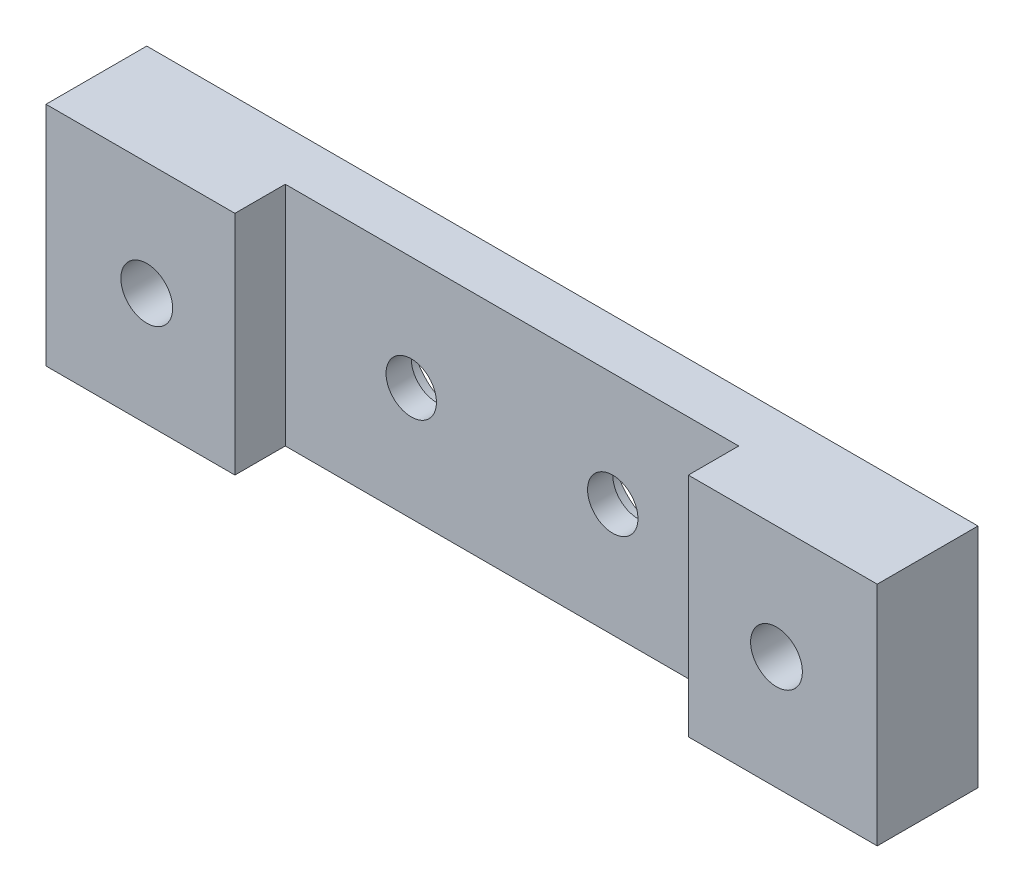
from build123d import *

# Parameters (mm, degrees)
BOSS_EXTRUDE1_DEPTH      = 28.575
HOLE1_D                  = 6.35
HOLE1_DEPTH              = 12.7
HOLE1_CBORE_D            = 12.7
HOLE1_CBORE_DEPTH        = 3.175
HOLE1_TIP                = 1.907732465
F_5_16_18_TAPPED_HOLE1_D = 6.5278


with BuildPart() as part:
    # Sketch1 → Boss-Extrude1 (new body)
    with BuildSketch(Plane(origin=(0, 0, 0), x_dir=(1, 0, 0), z_dir=(0, 1, 0))):
        Polygon((-52.3875, 0), (52.3875, 0), (52.3875, -12.7), (28.575, -12.7), (28.575, -6.35), (-28.575, -6.35), (-28.575, -12.7), (-52.3875, -12.7), align=None)
    extrude(amount=BOSS_EXTRUDE1_DEPTH)

    # Hole1
    with Locations(Plane(origin=(0, 0, 0), x_dir=(-1, 0, 0), z_dir=(0, 0, -1))):
        with Locations((-12.7, 14.2875), (12.7, 14.2875)):
            CounterBoreHole(HOLE1_D / 2, HOLE1_CBORE_D / 2, HOLE1_CBORE_DEPTH, depth=HOLE1_DEPTH)
            with Locations((0, 0, -(HOLE1_DEPTH + HOLE1_TIP / 2))):  # 118° drill point
                Cone(0, HOLE1_D / 2, HOLE1_TIP, mode=Mode.SUBTRACT)

    # 5/16-18 Tapped Hole1 (through all)
    with Locations(Plane.XY.offset(12.7)):
        with Locations((-39.6875, 14.2875), (39.6875, 14.2875)):
            Hole(F_5_16_18_TAPPED_HOLE1_D / 2)


solid = part.part
